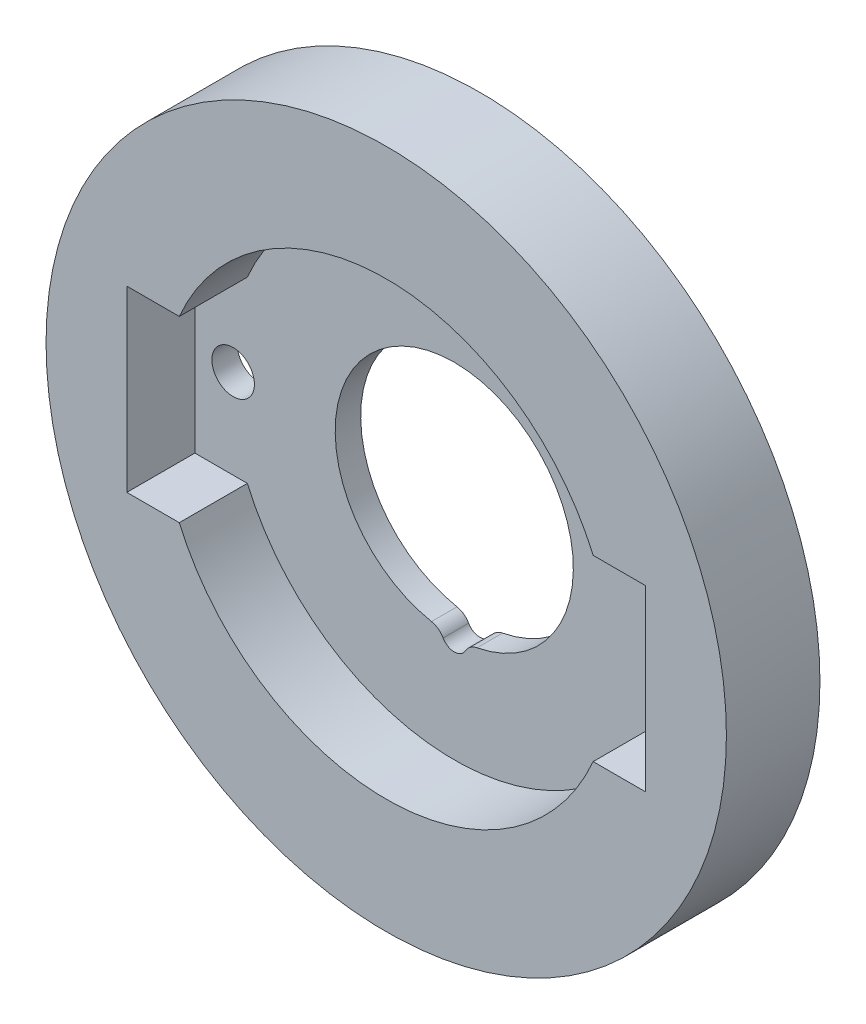
from build123d import *

# Parameters (mm, degrees)
SKIZZE1_R                       = 20
SKIZZE1_R_2                     = 7
AUFSATZ_LINEAR_AUSTRAGEN1_DEPTH = 5.5
SCHNITT_LINEAR_AUSTRAGEN1_DEPTH = 4
SCHNITT_LINEAR_AUSTRAGEN2_REACH = 7.5
SKIZZE3_R                       = 1.25
SCHNITT_LINEAR_AUSTRAGEN3_REACH = 3.5
SKIZZE4_R                       = 0.75
VERRUNDUNG1_R                   = 1


with BuildPart() as part:
    # Skizze1 → Aufsatz-Linear austragen1 (new body)
    with BuildSketch(Plane.XY):
        Circle(SKIZZE1_R)
        Circle(SKIZZE1_R_2, mode=Mode.SUBTRACT)
    extrude(amount=AUFSATZ_LINEAR_AUSTRAGEN1_DEPTH)

    # Skizze2 → Schnitt-Linear austragen1 (cut)
    with BuildSketch(Plane.XY.offset(5.5)):
        with BuildLine():
            Line((-4.630064794, -5.25), (-12.165525061, -5.25))
            ThreePointArc((-12.165525061, -5.25), (0, -13.25), (12.165525061, -5.25))
            Line((12.165525061, -5.25), (4.630064794, -5.25))
            ThreePointArc((4.630064794, -5.25), (0, -7), (-4.630064794, -5.25))
        make_face()
        with BuildLine():
            ThreePointArc((-12.165525061, 5.25), (-13.25, 0), (-12.165525061, -5.25))
            Line((-12.165525061, -5.25), (-4.630064794, -5.25))
            ThreePointArc((-4.630064794, -5.25), (-7, 0), (-4.630064794, 5.25))
            Line((-4.630064794, 5.25), (-12.165525061, 5.25))
        make_face()
        with BuildLine():
            Line((4.630064794, -5.25), (12.165525061, -5.25))
            ThreePointArc((12.165525061, -5.25), (12.976049226, -2.680419085), (13.25, 0))
            ThreePointArc((13.25, 0), (12.976049226, 2.680419085), (12.165525061, 5.25))
            Line((12.165525061, 5.25), (4.630064794, 5.25))
            ThreePointArc((4.630064794, 5.25), (6.380064794, 2.880064794), (7, 0))
            ThreePointArc((7, 0), (6.380064794, -2.880064794), (4.630064794, -5.25))
        make_face()
        with BuildLine():
            ThreePointArc((12.165525061, 5.25), (0, 13.25), (-12.165525061, 5.25))
            Line((-12.165525061, 5.25), (-4.630064794, 5.25))
            ThreePointArc((-4.630064794, 5.25), (0, 7), (4.630064794, 5.25))
            Line((4.630064794, 5.25), (12.165525061, 5.25))
        make_face()
        with BuildLine():
            Line((-15.25, 5.25), (-15.25, -5.25))
            Line((-15.25, -5.25), (-12.165525061, -5.25))
            ThreePointArc((-12.165525061, -5.25), (-13.25, 0), (-12.165525061, 5.25))
            Line((-12.165525061, 5.25), (-15.25, 5.25))
        make_face()
        with BuildLine():
            ThreePointArc((13.25, 0), (12.976049226, -2.680419085), (12.165525061, -5.25))
            Line((12.165525061, -5.25), (15.25, -5.25))
            Line((15.25, -5.25), (15.25, 5.25))
            Line((15.25, 5.25), (12.165525061, 5.25))
            ThreePointArc((12.165525061, 5.25), (12.976049226, 2.680419085), (13.25, 0))
        make_face()
    extrude(amount=-SCHNITT_LINEAR_AUSTRAGEN1_DEPTH, mode=Mode.SUBTRACT)

    # Skizze3 → Schnitt-Linear austragen2 (cut, up to next)
    with BuildSketch(Plane.XY.offset(5.5), mode=Mode.PRIVATE) as schnitt_linear_austragen2_sk1:
        with Locations((13, 0)):
            Circle(SKIZZE3_R)
    schnitt_linear_austragen2_tool1 = extrude(schnitt_linear_austragen2_sk1.sketch, amount=-SCHNITT_LINEAR_AUSTRAGEN2_REACH, mode=Mode.PRIVATE) & part.part
    add(schnitt_linear_austragen2_tool1.solids().sort_by_distance((13, 0, 5.5))[0], mode=Mode.SUBTRACT)
    # Skizze3 → Schnitt-Linear austragen2 (cut, up to next)
    with BuildSketch(Plane.XY.offset(5.5), mode=Mode.PRIVATE) as schnitt_linear_austragen2_sk2:
        with Locations((-13, 0)):
            Circle(SKIZZE3_R)
    schnitt_linear_austragen2_tool2 = extrude(schnitt_linear_austragen2_sk2.sketch, amount=-SCHNITT_LINEAR_AUSTRAGEN2_REACH, mode=Mode.PRIVATE) & part.part
    add(schnitt_linear_austragen2_tool2.solids().sort_by_distance((-13, 0, 5.5))[0], mode=Mode.SUBTRACT)

    # Skizze4 → Schnitt-Linear austragen3 (cut, up to next)
    with BuildSketch(Plane.XY.offset(1.5), mode=Mode.PRIVATE) as schnitt_linear_austragen3_sk1:
        with Locations((0, -7)):
            Circle(SKIZZE4_R)
    schnitt_linear_austragen3_tool1 = extrude(schnitt_linear_austragen3_sk1.sketch, amount=-SCHNITT_LINEAR_AUSTRAGEN3_REACH, mode=Mode.PRIVATE) & part.part
    add(schnitt_linear_austragen3_tool1.solids().sort_by_distance((0, -7, 1.5))[0], mode=Mode.SUBTRACT)

    # Verrundung1
    verrundung1_edges = [part.edges().sort_by_distance(p)[0] for p in [
        (-0.748923015, -6.959821429, 0.75),
        (0.748923015, -6.959821429, 0.75),
    ]]
    fillet(verrundung1_edges, radius=VERRUNDUNG1_R)


solid = part.part
